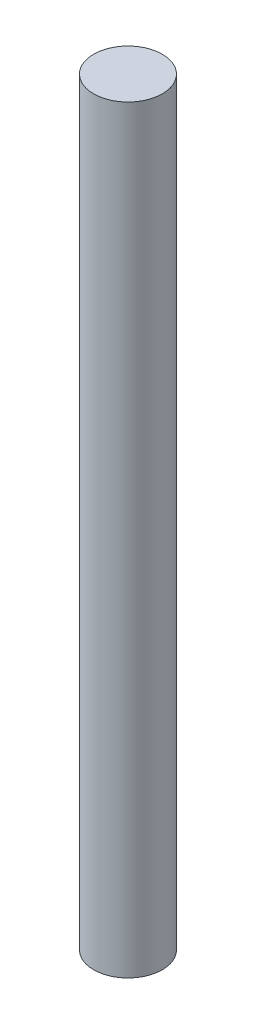
from build123d import *

# Parameters (mm, degrees)
SKETCH1_R           = 0.95
BOSS_EXTRUDE1_DEPTH = 21


with BuildPart() as part:
    # Sketch1 → Boss-Extrude1 (new body)
    with BuildSketch(Plane(origin=(0, 0, 0), x_dir=(1, 0, 0), z_dir=(0, 1, 0))):
        Circle(SKETCH1_R)
    extrude(amount=BOSS_EXTRUDE1_DEPTH)


solid = part.part
